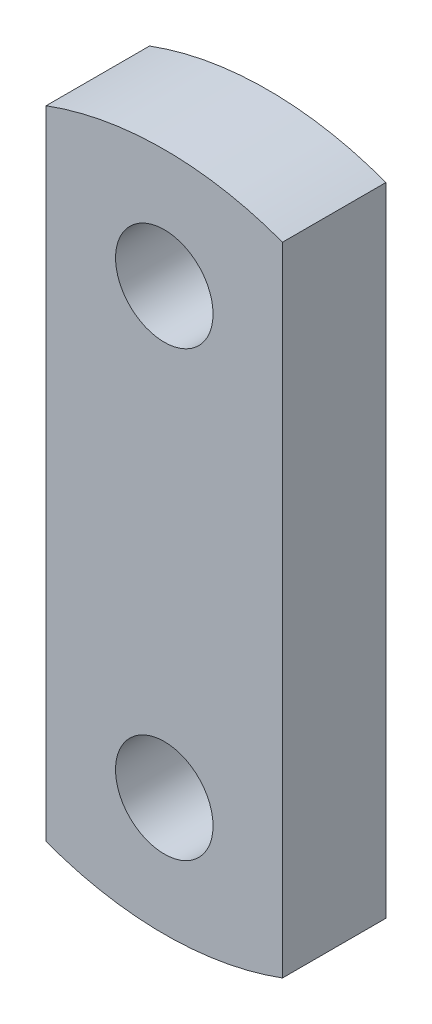
from build123d import *

# Parameters (mm, degrees)
SKETCH1_R           = 16.5
BOSS_EXTRUDE1_DEPTH = 35


with BuildPart() as part:
    # Sketch1 → Boss-Extrude1 (new body)
    with BuildSketch(Plane.XY):
        with BuildLine():
            Line((-57.372588678, 131.478151898), (-57.372588678, -84.160434631))
            ThreePointArc((-57.372588678, -84.160434631), (-97.372588678, -91.341141367), (-137.372588678, -84.160434631))
            Line((-137.372588678, -84.160434631), (-137.372588678, 131.478151898))
            ThreePointArc((-137.372588678, 131.478151898), (-97.372588678, 138.658858633), (-57.372588678, 131.478151898))
        make_face()
        with Locations((-97.372588678, 98.658858633)):
            Circle(SKETCH1_R, mode=Mode.SUBTRACT)
        with Locations((-97.372588678, -51.341141367)):
            Circle(SKETCH1_R, mode=Mode.SUBTRACT)
    extrude(amount=BOSS_EXTRUDE1_DEPTH)


solid = part.part
